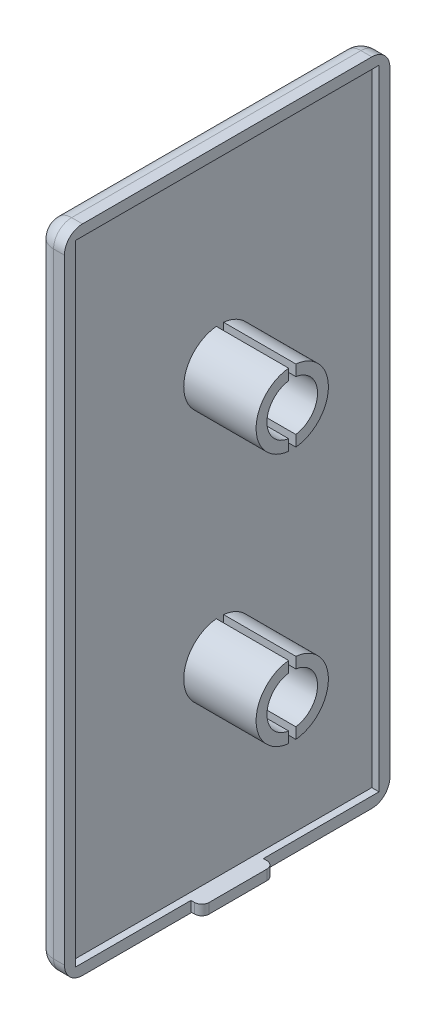
from build123d import *

# Parameters (mm, degrees)
EXTRUDE_3_DEPTH      = 22.5
EXTRUDE_3_DEPTH_BACK = 22.5
FILLET_3_R           = 2.5
SKETCH_6_W           = 42
SKETCH_6_H           = 87
CUT_EXTRUDE_2_DEPTH  = 1
EXTRUDE_5_DEPTH      = 10
SKETCH_9_W           = 10
SKETCH_9_H           = 1.4
EXTRUDE_6_DEPTH      = 1.5
FILLET_4_R           = 1


with BuildPart() as part:
    # Sketch 3 → Extrude 3 (new body, two sides)
    with BuildSketch(Plane.XY) as extrude_3_sk:
        with BuildLine():
            Line((0.5, -45), (2, -45))
            Line((2, -45), (2, 45))
            Line((2, 45), (0.5, 45))
            ThreePointArc((0.5, 45), (-1.267766953, 44.267766953), (-2, 42.5))
            Line((-2, 42.5), (-2, -42.5))
            ThreePointArc((-2, -42.5), (-1.267766953, -44.267766953), (0.5, -45))
        make_face()
    extrude(amount=EXTRUDE_3_DEPTH)
    extrude(extrude_3_sk.sketch, amount=-EXTRUDE_3_DEPTH_BACK)

    # Fillet 3
    fillet_3_edges = [part.edges().sort_by_distance(p)[0] for p in [
        (-1.267766953, 44.267766953, -22.5),
        (-2, 0, -22.5),
        (1.25, 45, 22.5),
        (-1.267766953, 44.267766953, 22.5),
        (-2, 0, 22.5),
        (-1.267766953, -44.267766953, 22.5),
        (1.25, -45, 22.5),
        (-1.267766953, -44.267766953, -22.5),
        (1.25, -45, -22.5),
        (1.25, 45, -22.5),
    ]]
    fillet(fillet_3_edges, radius=FILLET_3_R)

    # Sketch 6 → Cut-Extrude 2 (cut)
    with BuildSketch(Plane(origin=(2, 0, 0), x_dir=(0, 0, -1), z_dir=(1, 0, 0))):
        Rectangle(SKETCH_6_W, SKETCH_6_H)
    extrude(amount=-CUT_EXTRUDE_2_DEPTH, mode=Mode.SUBTRACT)

    # Sketch 7 → Extrude 5 (add)
    with BuildSketch(Plane(origin=(1, 0, 0), x_dir=(0, 0, -1), z_dir=(1, 0, 0))):
        with BuildLine():
            Line((-0.5, 22.474937186), (-0.5, 20.964101615))
            ThreePointArc((-0.5, 20.964101615), (-3.5, 17.5), (-0.5, 14.035898385))
            Line((-0.5, 14.035898385), (-0.5, 12.525062814))
            ThreePointArc((-0.5, 12.525062814), (-5, 17.5), (-0.5, 22.474937186))
        make_face()
        with BuildLine():
            Line((0.5, 22.474937186), (0.5, 20.964101615))
            ThreePointArc((0.5, 20.964101615), (3.5, 17.5), (0.5, 14.035898385))
            Line((0.5, 14.035898385), (0.5, 12.525062814))
            ThreePointArc((0.5, 12.525062814), (5, 17.5), (0.5, 22.474937186))
        make_face()
        with BuildLine():
            Line((-0.5, -14.035898385), (-0.5, -12.525062814))
            ThreePointArc((-0.5, -12.525062814), (-5, -17.5), (-0.5, -22.474937186))
            Line((-0.5, -22.474937186), (-0.5, -20.964101615))
            ThreePointArc((-0.5, -20.964101615), (-3.5, -17.5), (-0.5, -14.035898385))
        make_face()
        with BuildLine():
            Line((0.5, -14.035898385), (0.5, -12.525062814))
            ThreePointArc((0.5, -12.525062814), (5, -17.5), (0.5, -22.474937186))
            Line((0.5, -22.474937186), (0.5, -20.964101615))
            ThreePointArc((0.5, -20.964101615), (3.5, -17.5), (0.5, -14.035898385))
        make_face()
    extrude(amount=EXTRUDE_5_DEPTH)

    # Sketch 9 → Extrude 6 (add)
    with BuildSketch(Plane(origin=(2, 0, 0), x_dir=(0, 0, -1), z_dir=(1, 0, 0))):
        with Locations((0, -44.2)):
            Rectangle(SKETCH_9_W, SKETCH_9_H)
    extrude(amount=EXTRUDE_6_DEPTH)

    # Fillet 4
    fillet_4_edges = [part.edges().sort_by_distance(p)[0] for p in [
        (3.5, -44.2, 5),
        (3.5, -44.2, -5),
    ]]
    fillet(fillet_4_edges, radius=FILLET_4_R)


solid = part.part
